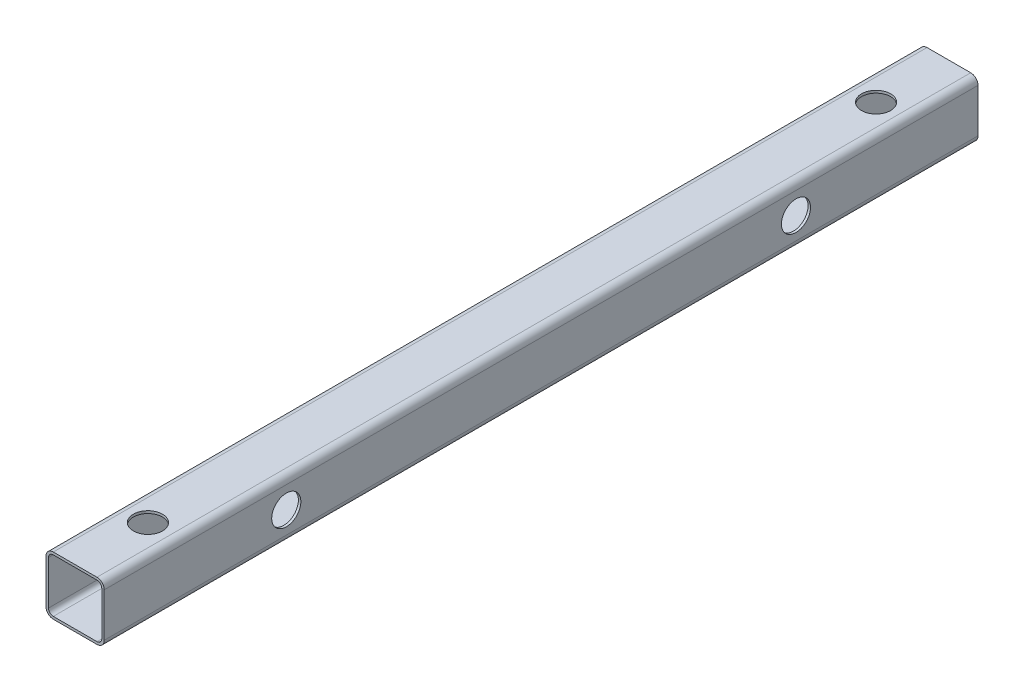
from build123d import *

# Parameters (mm, degrees)
BOSS_EXTRUDE1_DEPTH      = 120
BOSS_EXTRUDE1_DEPTH_BACK = 120
CUT_EXTRUDE1_DEPTH       = 122.326007105
CUT_EXTRUDE1_DEPTH_BACK  = 122.326007105
SKETCH2_R                = 4
CUT_EXTRUDE2_DEPTH       = 122.326007105
CUT_EXTRUDE2_DEPTH_BACK  = 122.326007105
SKETCH3_R                = 4


with BuildPart() as part:
    # Sketch1 → Boss-Extrude1 (new, two sides: drawn at the far end of the back side and taken through both)
    with BuildSketch(Plane.XY.offset(-BOSS_EXTRUDE1_DEPTH_BACK)):
        with BuildLine():
            Line((-6, -8), (6, -8))
            ThreePointArc((6, -8), (7.414213562, -7.414213562), (8, -6))
            Line((8, -6), (8, 6))
            ThreePointArc((8, 6), (7.414213562, 7.414213562), (6, 8))
            Line((6, 8), (-6, 8))
            ThreePointArc((-6, 8), (-7.414213562, 7.414213562), (-8, 6))
            Line((-8, 6), (-8, -6))
            ThreePointArc((-8, -6), (-7.414213562, -7.414213562), (-6, -8))
        make_face()
        with BuildLine():
            Line((-6, 7.32), (6, 7.32))
            ThreePointArc((6, 7.32), (6.933380951, 6.933380951), (7.32, 6))
            Line((7.32, 6), (7.32, -6))
            ThreePointArc((7.32, -6), (6.933380951, -6.933380951), (6, -7.32))
            Line((6, -7.32), (-6, -7.32))
            ThreePointArc((-6, -7.32), (-6.933380951, -6.933380951), (-7.32, -6))
            Line((-7.32, -6), (-7.32, 6))
            ThreePointArc((-7.32, 6), (-6.933380951, 6.933380951), (-6, 7.32))
        make_face(mode=Mode.SUBTRACT)
    extrude(amount=BOSS_EXTRUDE1_DEPTH + BOSS_EXTRUDE1_DEPTH_BACK)

    # Sketch2 → Cut-Extrude1 (cut, two sides: drawn at the far end of the back side and taken through both)
    with BuildSketch(Plane(origin=(0, 8, 0), x_dir=(1, 0, 0), z_dir=(0, 1, 0)).offset(-CUT_EXTRUDE1_DEPTH_BACK)):
        with Locations((0, -100)):
            Circle(SKETCH2_R)
        with Locations((0, 100)):
            Circle(SKETCH2_R)
    extrude(amount=CUT_EXTRUDE1_DEPTH + CUT_EXTRUDE1_DEPTH_BACK, mode=Mode.SUBTRACT)

    # Sketch3 → Cut-Extrude2 (cut, two sides: drawn at the far end of the back side and taken through both)
    with BuildSketch(Plane(origin=(8, 0, 0), x_dir=(0, 0, -1), z_dir=(1, 0, 0)).offset(-CUT_EXTRUDE2_DEPTH_BACK)):
        with Locations((-70, 0)):
            Circle(SKETCH3_R)
        with Locations((70, 0)):
            Circle(SKETCH3_R)
    extrude(amount=CUT_EXTRUDE2_DEPTH + CUT_EXTRUDE2_DEPTH_BACK, mode=Mode.SUBTRACT)


solid = part.part
